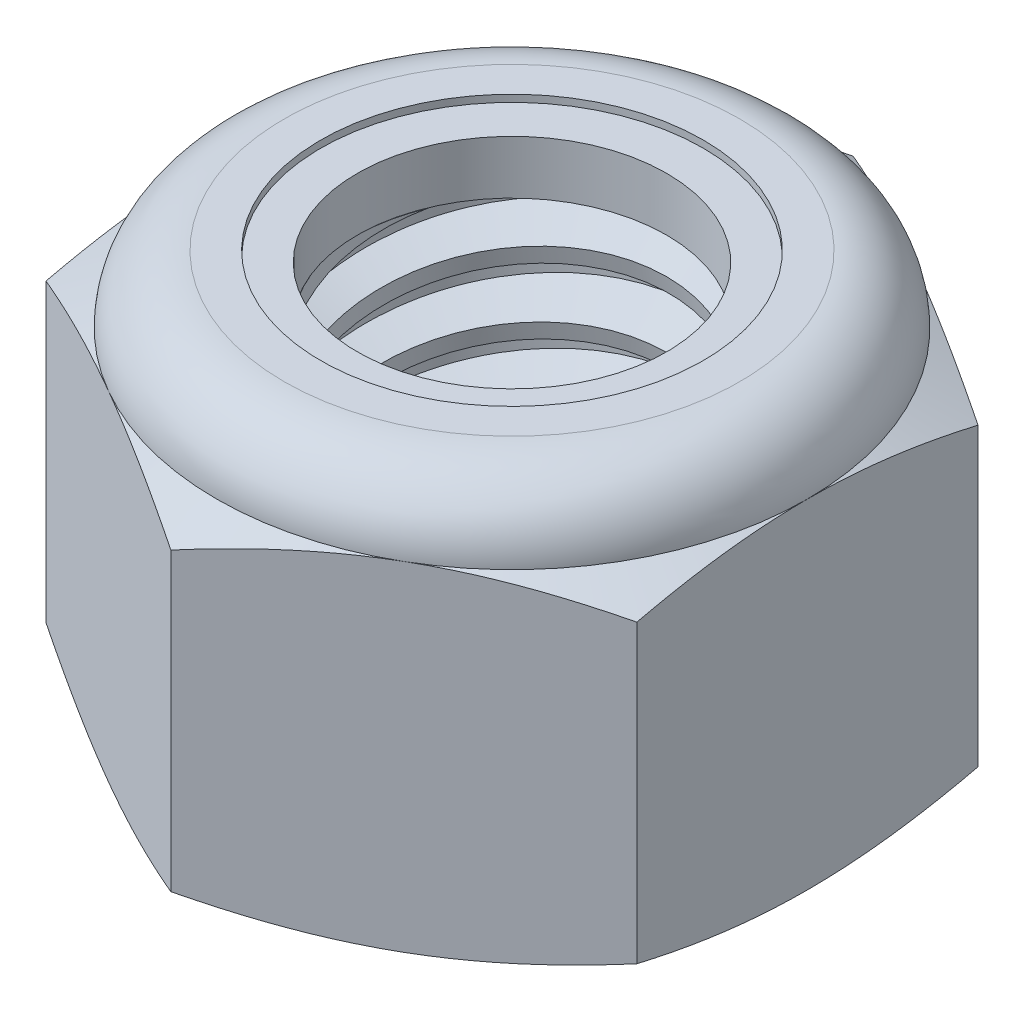
from build123d import *

# Parameters (mm, degrees)
EXTRUDE1_DEPTH       = 8.73125
SKETCH2_W            = 3.96875
SKETCH2_H            = 8.73125
LPATTERN1_COUNT      = 6
LPATTERN1_PITCH      = 1.411111111
LPATTERN1_COUNT_DIR2 = 2
LPATTERN1_PITCH_DIR2 = 1.411111111


with BuildPart() as part:
    # Sketch1 → Extrude1 (new body)
    with BuildSketch(Plane(origin=(0, 0, 0), x_dir=(1, 0, 0), z_dir=(0, 1, 0))):
        Polygon((0, 7.332348419), (-6.35, 3.666174209), (-6.35, -3.666174209), (0, -7.332348419), (6.35, -3.666174209), (6.35, 3.666174209), align=None)
    extrude(amount=EXTRUDE1_DEPTH)

    # Sketch4 → Cut-Revolve2 (revolve, cut)
    with BuildSketch(Plane(origin=(0, 0, 0), x_dir=(0, 0, -1), z_dir=(1, 0, 0))):
        Polygon((0, 8.73125), (3.96875, 8.73125), (3.324813425, 8.430977444), (3.324813425, 0.300272556), (3.96875, 0), (0, 0), align=None)
    revolve(axis=Axis((0, 8.73125, 0), (0, 1, 0)), mode=Mode.SUBTRACT)


with BuildPart() as body_2:
    # Sketch2 → Revolve1 (revolve)
    with BuildSketch(Plane(origin=(0, 0, 0), x_dir=(0, 0, -1), z_dir=(1, 0, 0))):
        with Locations((1.984375, 4.365625)):
            Rectangle(SKETCH2_W, SKETCH2_H)
    revolve(axis=Axis((0, -3.96875, 0), (0, 1, 0)))

    # Sketch3 → Cut-Revolve1 (revolve, cut)
    with BuildSketch(Plane(origin=(0, 0, 0), x_dir=(0, 0, -1), z_dir=(1, 0, 0))):
        Polygon((3.999623935, 8.557584113), (4.215741483, 7.341922906), (3.386561296, 7.642399561), (3.324813425, 7.989731334), align=None)
    cut_revolve1 = revolve(axis=Axis((0, 8.73125, 0.268755768), (0, -0.984562508, -0.175033335)), mode=Mode.SUBTRACT)

    # LPattern1: Cut-Revolve1 6 × 2
    with Locations(*[Vector(0, -1, 0) * (i * LPATTERN1_PITCH) + Vector(0, 1, 0) * (j * LPATTERN1_PITCH_DIR2) for i in range(LPATTERN1_COUNT) for j in range(LPATTERN1_COUNT_DIR2) if (i, j) != (0, 0)]):
        add(cut_revolve1, mode=Mode.SUBTRACT)


with BuildPart() as part_1:
    add(part.part)

    # Combine1: cut body 2
    add(body_2.part, mode=Mode.SUBTRACT)

    # Sketch5 → Cut-Revolve3 (revolve, cut)
    with BuildSketch(Plane(origin=(0, 0, 0), x_dir=(0, 0, -1), z_dir=(1, 0, 0))):
        with BuildLine():
            Line((0, 0), (6.35, 0))
            Line((6.35, 0), (7.332348419, 0.458076591))
            Line((7.332348419, 0.458076591), (7.332348419, 6.817965076))
            Line((7.332348419, 6.817965076), (6.35, 7.276041667))
            ThreePointArc((6.35, 7.276041667), (5.923779347, 8.305029347), (4.894791667, 8.73125))
            Line((4.894791667, 8.73125), (4.894791667, 10.00125))
            Line((4.894791667, 10.00125), (8.602348419, 10.00125))
            Line((8.602348419, 10.00125), (8.602348419, -1.27))
            Line((8.602348419, -1.27), (0, -1.27))
            Line((0, -1.27), (0, 0))
        make_face()
    revolve(axis=Axis((0, 0, 0), (0, 1, 0)), mode=Mode.SUBTRACT)

    # Sketch6 → Cut-Revolve4 (revolve, cut)
    with BuildSketch(Plane(origin=(0, 0, 0), x_dir=(0, 0, -1), z_dir=(1, 0, 0))):
        with BuildLine():
            Line((0, 7.276041667), (6.1976, 7.276041667))
            ThreePointArc((6.1976, 7.276041667), (5.816016274, 8.197266274), (4.894791667, 8.57885))
            Line((4.894791667, 8.57885), (4.109802546, 8.57885))
            Line((4.109802546, 8.57885), (4.109802546, 10.00125))
            Line((4.109802546, 10.00125), (0, 10.00125))
            Line((0, 10.00125), (0, 7.276041667))
        make_face()
    revolve(axis=Axis((0, 10.00125, 0), (0, 1, 0)), mode=Mode.SUBTRACT)


with BuildPart() as body_2_2:
    # Sketch7 → Revolve2 (revolve)
    with BuildSketch(Plane(origin=(0, 0, 0), x_dir=(0, 0, -1), z_dir=(1, 0, 0))):
        with BuildLine():
            Line((3.324813425, 7.352241667), (6.119030844, 7.352241667))
            ThreePointArc((6.119030844, 7.352241667), (5.734762038, 8.169919611), (4.894791667, 8.50265))
            Line((4.894791667, 8.50265), (3.324813425, 8.50265))
            Line((3.324813425, 8.50265), (3.324813425, 7.352241667))
        make_face()
    revolve(axis=Axis((0, 7.352241667, 0), (0, 1, 0)))


solid = Compound([part_1.part, body_2_2.part])
